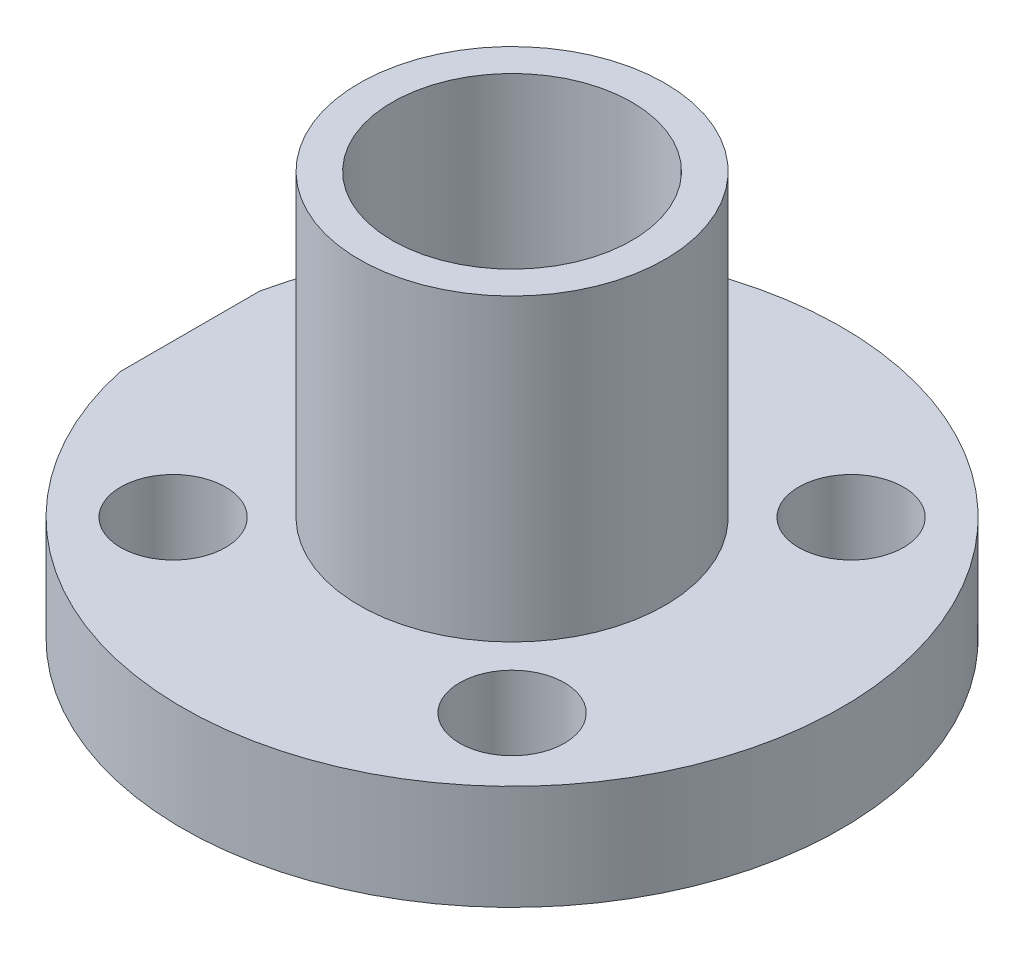
from build123d import *

# Parameters (mm, degrees)
F_3_5_3_5_DURCHMESSER_BOHRUNG1_D = 3.5
SKIZZE5_W                        = 0.5
SKIZZE5_H                        = 50
SCHNITT_LINEAR_AUSTRAGEN1_DEPTH  = 6


with BuildPart() as part:
    # Skizze1 → Rotation1 (revolve)
    with BuildSketch(Plane.XY):
        Polygon((-4, 0), (-4, 13.5), (-5.1, 13.5), (-5.1, 3.5), (-11, 3.5), (-11, 0), (-5.1, 0), (-5.1, -1.5), (-4, -1.5), align=None)
    revolve(axis=Axis((0, 0, 0), (0, 1, 0)))

    # Ø3.5 (3.5) Durchmesser Bohrung1 (through all)
    with Locations(Plane(origin=(0, 3.5, 0), x_dir=(1, 0, 0), z_dir=(0, 1, 0))):
        with Locations((5.656854249, 5.656854249), (-5.656854249, 5.656854249), (5.656854249, -5.656854249), (-5.656854249, -5.656854249)):
            Hole(F_3_5_3_5_DURCHMESSER_BOHRUNG1_D / 2)

    # Skizze5 → Schnitt-Linear austragen1 (cut, through all)
    with BuildSketch(Plane(origin=(0, 3.5, 0), x_dir=(1, 0, 0), z_dir=(0, 1, 0))):
        with Locations((-11, 0)):
            Rectangle(SKIZZE5_W, SKIZZE5_H)
    extrude(amount=-SCHNITT_LINEAR_AUSTRAGEN1_DEPTH, mode=Mode.SUBTRACT)


solid = part.part
